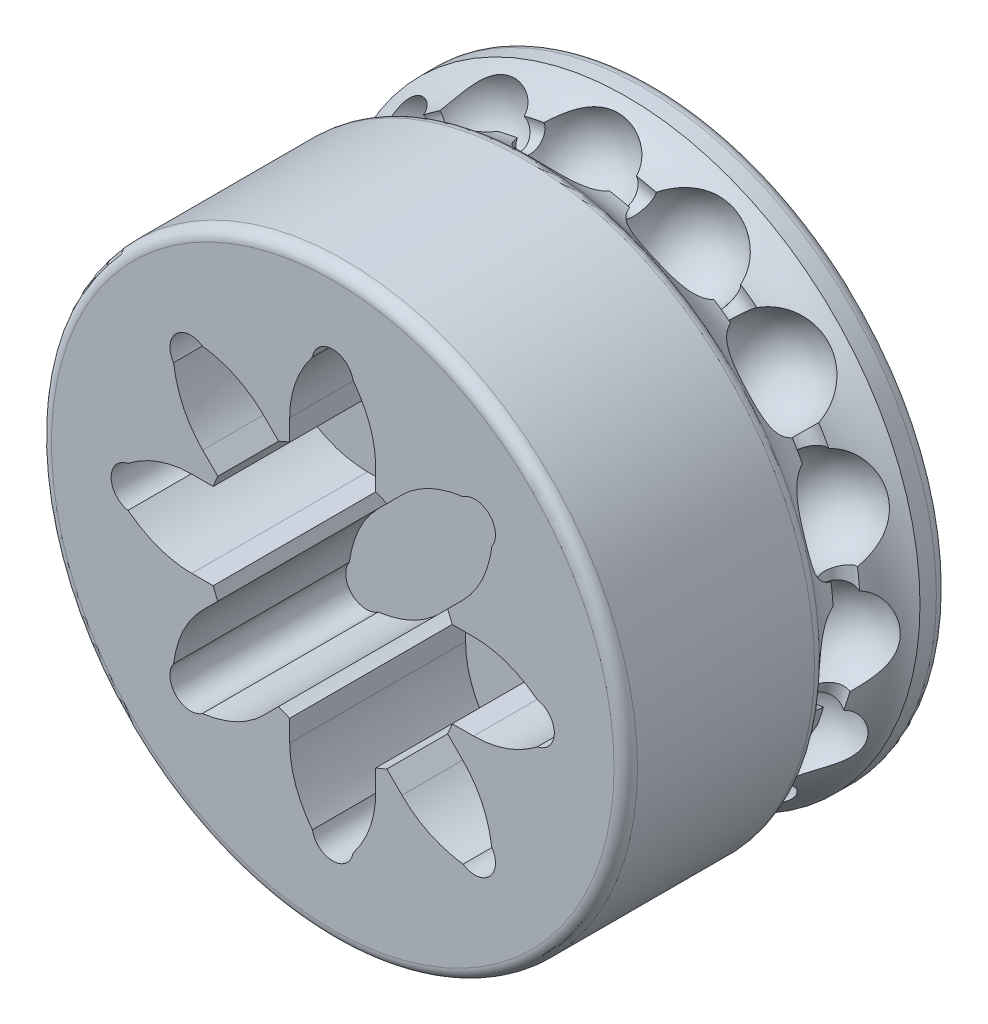
from build123d import *

# Parameters (mm, degrees)
ESBO_O1_R                     = 15
RESSALTO_EXTRUS_O1_DEPTH      = 4
PADR_OCIRCULAR1_COUNT         = 15
VARREDURA_DE_CORTE3_PROFILE_R = 3.25
VARREDURA_DE_CORTE5_PROFILE_R = 0.75
ESBO_O244_R                   = 15
CORTE_EXTRUS_O1_DEPTH         = 9
FILETE1_R                     = 0.6


with BuildPart() as part:
    # Esboço1 → Ressalto-extrusão1 (new, symmetric)
    with BuildSketch(Plane.XY):
        Circle(ESBO_O1_R)
    extrude(amount=RESSALTO_EXTRUS_O1_DEPTH, both=True)

    # Esboço2 → Corte-Revolução1 (revolve, cut)
    with BuildSketch(Plane.XY):
        with BuildLine():
            Line((0, 10.668114618), (0, 15.668114618))
            ThreePointArc((0, 15.668114618), (-2.5, 13.168114618), (0, 10.668114618))
        make_face()
    corte_revolu_o1 = revolve(axis=Axis((0, 10.668114618, 0), (0, 1, 0)), mode=Mode.SUBTRACT)

    # PadrãoCircular1: Corte-Revolução1 ×15 about axis
    padr_ocircular1_axis = Axis((0, 0, 0), (0, 0, 1))
    for i in range(1, PADR_OCIRCULAR1_COUNT):
        add(corte_revolu_o1.rotate(padr_ocircular1_axis, i * 360 / PADR_OCIRCULAR1_COUNT), mode=Mode.SUBTRACT)

    # Varredura de corte3: sweep along a path in Esboço138
    with BuildLine(Plane.XY) as varredura_de_corte3_path:
        CenterArc((0, 0), 17, 0, 360)
    # Varredura de corte3 profile (on start of the path) → Varredura de corte3 (sweep, cut)
    with BuildSketch(Plane(origin=(17, 0, 0), x_dir=(0, 0, 1), z_dir=(0, 1, 0))):
        Circle(VARREDURA_DE_CORTE3_PROFILE_R)
    sweep(path=varredura_de_corte3_path.line, mode=Mode.SUBTRACT)

    # Varredura de corte5: sweep along a path in Esboço219
    with BuildLine(Plane.XY) as varredura_de_corte5_path:
        CenterArc((0, 0), 13.5, 0, 360)
    # Varredura de corte5 profile (on start of the path) → Varredura de corte5 (sweep, cut)
    with BuildSketch(Plane(origin=(13.5, 0, 0), x_dir=(0, 0, 1), z_dir=(0, 1, 0))):
        Circle(VARREDURA_DE_CORTE5_PROFILE_R)
    sweep(path=varredura_de_corte5_path.line, mode=Mode.SUBTRACT)

    # Esboço244 → section 0 of loft1
    with BuildSketch(Plane.XY.offset(12.5), mode=Mode.PRIVATE) as loft1_s0:
        Circle(ESBO_O244_R)
    # loft up to a face of the part (loft1)
    loft([loft1_s0.sketch, Face(Wire([part.edges().sort_by_distance((-10.268206589, 10.934529411, 4))[0]]))])

    # Esboço248 → Corte-extrusão1 (cut)
    with BuildSketch(Plane.XY.offset(12.5)):
        with BuildLine():
            Line((-6.116371473, 2.2), (-7.212320385, 2.2))
            add(Edge.make_bspline(
                [(-7.212320385, 2.2), (-7.786480783, 2.2), (-8.650732675, 2.051074223), (-9.715574754, 1.568402691), (-10.236196244, 1.225967887), (-10.479179883, 1.040805932)],
                knots=[0, 0, 0, 0, 0.481197684, 0.721796527, 0.962395369, 0.962395369, 0.962395369, 0.962395369], degree=3))
            ThreePointArc((-10.479179883, 1.040805932), (-11.343128892, 0), (-10.479179883, -1.040805932))
            add(Edge.make_bspline(
                [(-10.479179883, -1.040805932), (-10.236196244, -1.225967887), (-9.715574754, -1.568402691), (-8.650732675, -2.051074223), (-7.786480783, -2.2), (-7.212320385, -2.2)],
                knots=[0, 0, 0, 0, 0.240598842, 0.481197684, 0.962395369, 0.962395369, 0.962395369, 0.962395369], degree=3))
            Line((-7.212320385, -2.2), (-6.116371473, -2.2))
            ThreePointArc((-6.116371473, -2.2), (-6.005216961, -2.48744231), (-5.880562664, -2.769292826))
            Line((-5.880562664, -2.769292826), (-6.655515571, -3.544245734))
            add(Edge.make_bspline(
                [(-6.655515571, -3.544245734), (-7.061508282, -3.950238445), (-7.567320229, -4.666663245), (-7.978976971, -5.760920613), (-8.104973984, -6.371193572), (-8.145860089, -6.673938224)],
                knots=[0, 0, 0, 0, 0.481197684, 0.721796527, 0.962395369, 0.962395369, 0.962395369, 0.962395369], degree=3))
            ThreePointArc((-8.145860089, -6.673938224), (-8.02080336, -8.02080336), (-6.673938224, -8.145860089))
            add(Edge.make_bspline(
                [(-6.673938224, -8.145860089), (-6.371193572, -8.104973984), (-5.760920613, -7.978976971), (-4.666663245, -7.567320229), (-3.950238445, -7.061508282), (-3.544245734, -6.655515571)],
                knots=[0, 0, 0, 0, 0.240598842, 0.481197684, 0.962395369, 0.962395369, 0.962395369, 0.962395369], degree=3))
            Line((-3.544245734, -6.655515571), (-2.769292826, -5.880562664))
            ThreePointArc((-2.769292826, -5.880562664), (-2.48744231, -6.005216961), (-2.2, -6.116371473))
            Line((-2.2, -6.116371473), (-2.2, -7.212320385))
            add(Edge.make_bspline(
                [(-2.2, -7.212320385), (-2.2, -7.786480783), (-2.051074223, -8.650732675), (-1.568402691, -9.715574754), (-1.225967887, -10.236196244), (-1.040805932, -10.479179883)],
                knots=[0, 0, 0, 0, 0.481197684, 0.721796527, 0.962395369, 0.962395369, 0.962395369, 0.962395369], degree=3))
            ThreePointArc((-1.040805932, -10.479179883), (0, -11.343128892), (1.040805932, -10.479179883))
            add(Edge.make_bspline(
                [(1.040805932, -10.479179883), (1.225967887, -10.236196244), (1.568402691, -9.715574754), (2.051074223, -8.650732675), (2.2, -7.786480783), (2.2, -7.212320385)],
                knots=[0, 0, 0, 0, 0.240598842, 0.481197684, 0.962395369, 0.962395369, 0.962395369, 0.962395369], degree=3))
            Line((2.2, -7.212320385), (2.2, -6.116371473))
            ThreePointArc((2.2, -6.116371473), (2.48744231, -6.005216961), (2.769292826, -5.880562664))
            Line((2.769292826, -5.880562664), (3.544245734, -6.655515571))
            add(Edge.make_bspline(
                [(3.544245734, -6.655515571), (3.950238445, -7.061508282), (4.666663245, -7.567320229), (5.760920613, -7.978976971), (6.371193572, -8.104973984), (6.673938224, -8.145860089)],
                knots=[0, 0, 0, 0, 0.481197684, 0.721796527, 0.962395369, 0.962395369, 0.962395369, 0.962395369], degree=3))
            ThreePointArc((6.673938224, -8.145860089), (8.02080336, -8.02080336), (8.145860089, -6.673938224))
            add(Edge.make_bspline(
                [(8.145860089, -6.673938224), (8.104973984, -6.371193572), (7.978976971, -5.760920613), (7.567320229, -4.666663245), (7.061508282, -3.950238445), (6.655515571, -3.544245734)],
                knots=[0, 0, 0, 0, 0.240598842, 0.481197684, 0.962395369, 0.962395369, 0.962395369, 0.962395369], degree=3))
            Line((6.655515571, -3.544245734), (5.880562664, -2.769292826))
            ThreePointArc((5.880562664, -2.769292826), (6.005216961, -2.48744231), (6.116371473, -2.2))
            Line((6.116371473, -2.2), (7.212320385, -2.2))
            add(Edge.make_bspline(
                [(7.212320385, -2.2), (7.786480783, -2.2), (8.650732675, -2.051074223), (9.715574754, -1.568402691), (10.236196244, -1.225967887), (10.479179883, -1.040805932)],
                knots=[0.037604631, 0.037604631, 0.037604631, 0.037604631, 0.518802316, 0.759401158, 1, 1, 1, 1], degree=3))
            ThreePointArc((10.479179883, -1.040805932), (11.343128892, 0), (10.479179883, 1.040805932))
            add(Edge.make_bspline(
                [(10.479179883, 1.040805932), (10.236196244, 1.225967887), (9.715574754, 1.568402691), (8.650732675, 2.051074223), (7.786480783, 2.2), (7.212320385, 2.2)],
                knots=[0, 0, 0, 0, 0.240598842, 0.481197684, 0.962395369, 0.962395369, 0.962395369, 0.962395369], degree=3))
            Line((7.212320385, 2.2), (6.116371473, 2.2))
            ThreePointArc((6.116371473, 2.2), (6.005216961, 2.48744231), (5.880562664, 2.769292826))
            Line((5.880562664, 2.769292826), (6.655515571, 3.544245734))
            add(Edge.make_bspline(
                [(6.655515571, 3.544245734), (7.061508282, 3.950238445), (7.567320229, 4.666663245), (7.978976971, 5.760920613), (8.104973984, 6.371193572), (8.145860089, 6.673938224)],
                knots=[0.037604631, 0.037604631, 0.037604631, 0.037604631, 0.518802316, 0.759401158, 1, 1, 1, 1], degree=3))
            ThreePointArc((8.145860089, 6.673938224), (8.02080336, 8.02080336), (6.673938224, 8.145860089))
            add(Edge.make_bspline(
                [(6.673938224, 8.145860089), (6.371193572, 8.104973984), (5.760920613, 7.978976971), (4.666663245, 7.567320229), (3.950238445, 7.061508282), (3.544245734, 6.655515571)],
                knots=[0, 0, 0, 0, 0.240598842, 0.481197684, 0.962395369, 0.962395369, 0.962395369, 0.962395369], degree=3))
            Line((3.544245734, 6.655515571), (2.769292826, 5.880562664))
            ThreePointArc((2.769292826, 5.880562664), (2.48744231, 6.005216961), (2.2, 6.116371473))
            Line((2.2, 6.116371473), (2.2, 7.212320385))
            add(Edge.make_bspline(
                [(2.2, 7.212320385), (2.2, 7.786480783), (2.051074223, 8.650732675), (1.568402691, 9.715574754), (1.225967887, 10.236196244), (1.040805932, 10.479179883)],
                knots=[0.037604631, 0.037604631, 0.037604631, 0.037604631, 0.518802316, 0.759401158, 1, 1, 1, 1], degree=3))
            ThreePointArc((1.040805932, 10.479179883), (0, 11.343128892), (-1.040805932, 10.479179883))
            add(Edge.make_bspline(
                [(-1.040805932, 10.479179883), (-1.225967887, 10.236196244), (-1.568402691, 9.715574754), (-2.051074223, 8.650732675), (-2.2, 7.786480783), (-2.2, 7.212320385)],
                knots=[0.037604631, 0.037604631, 0.037604631, 0.037604631, 0.278203473, 0.518802316, 1, 1, 1, 1], degree=3))
            Line((-2.2, 7.212320385), (-2.2, 6.116371473))
            ThreePointArc((-2.2, 6.116371473), (-2.48744231, 6.005216961), (-2.769292826, 5.880562664))
            Line((-2.769292826, 5.880562664), (-3.544245734, 6.655515571))
            add(Edge.make_bspline(
                [(-3.544245734, 6.655515571), (-3.950238445, 7.061508282), (-4.666663245, 7.567320229), (-5.760920613, 7.978976971), (-6.371193572, 8.104973984), (-6.673938224, 8.145860089)],
                knots=[0, 0, 0, 0, 0.481197684, 0.721796527, 0.962395369, 0.962395369, 0.962395369, 0.962395369], degree=3))
            ThreePointArc((-6.673938224, 8.145860089), (-8.02080336, 8.02080336), (-8.145860089, 6.673938224))
            add(Edge.make_bspline(
                [(-8.145860089, 6.673938224), (-8.104973984, 6.371193572), (-7.978976971, 5.760920613), (-7.567320229, 4.666663245), (-7.061508282, 3.950238445), (-6.655515571, 3.544245734)],
                knots=[0, 0, 0, 0, 0.240598842, 0.481197684, 0.962395369, 0.962395369, 0.962395369, 0.962395369], degree=3))
            Line((-6.655515571, 3.544245734), (-5.880562664, 2.769292826))
            ThreePointArc((-5.880562664, 2.769292826), (-6.005216961, 2.48744231), (-6.116371473, 2.2))
        make_face()
    extrude(amount=-CORTE_EXTRUS_O1_DEPTH, mode=Mode.SUBTRACT)

    # Filete1
    filete1_edges = [part.edges().sort_by_distance(p)[0] for p in [
        (-15, 0, 12.5),
        (-15, 0, -4),
        (-15, 0, 2.561737691),
    ]]
    fillet(filete1_edges, radius=FILETE1_R)


solid = part.part
